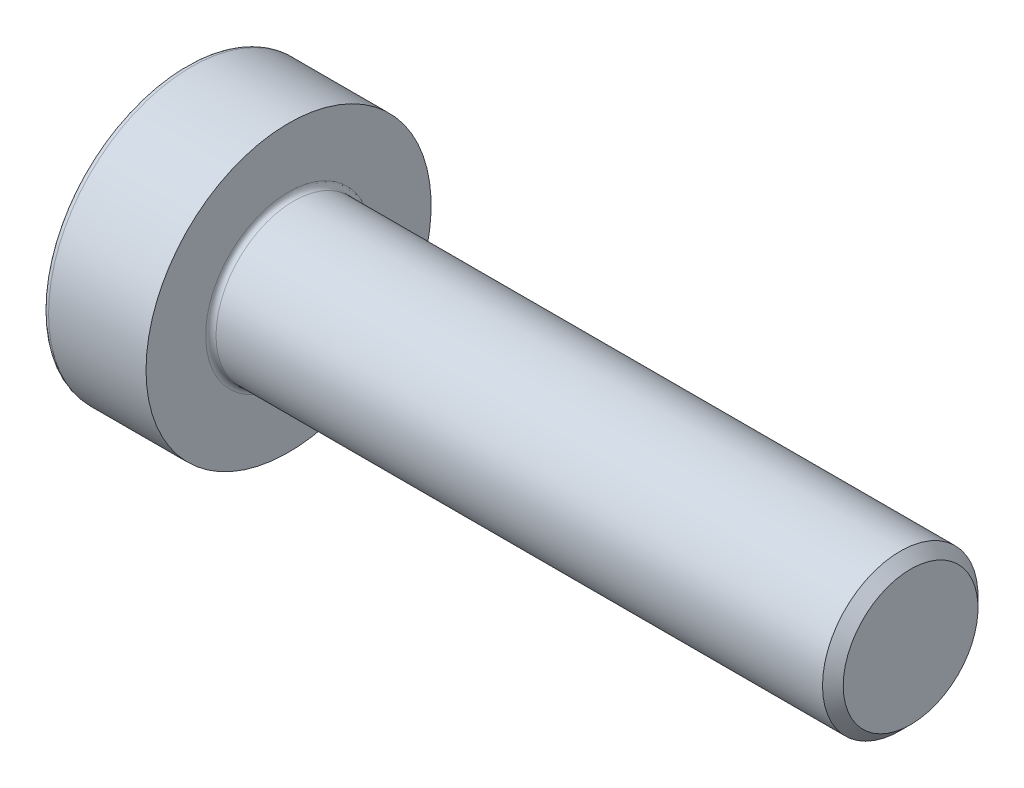
from build123d import *

# Parameters (mm, degrees)
FILLET1_R      = 0.1
FILLET2_R      = 0.12
CHAMFER1_SIZE  = 0.2
EXTRUDE1_DEPTH = 1


with BuildPart() as part:
    # Sketch1 → Revolve1 (revolve)
    with BuildSketch(Plane.XY, mode=Mode.PRIVATE) as revolve1_sk:
        Polygon((2, 1.5), (2, 0), (4.279914881, 0), (14, 0), (14, 1.5), align=None)
        Polygon((0, 2.75), (0, 0), (2, 0), (2, 1.5), (2, 2.75), align=None)
    revolve(revolve1_sk.sketch.rotate(Axis((0, 0, 0), (1, 0, 0)), 90), axis=Axis((0, 0, 0), (1, 0, 0)))

    # Fillet1
    fillet1_edges = [part.edges().sort_by_distance(p)[0] for p in [
        (2, 0, -1.5),
    ]]
    fillet(fillet1_edges, radius=FILLET1_R)

    # Fillet2
    fillet2_edges = [part.edges().sort_by_distance(p)[0] for p in [
        (0, 0, -2.75),
    ]]
    fillet(fillet2_edges, radius=FILLET2_R)

    # Chamfer1
    chamfer1_edges = [part.edges().sort_by_distance(p)[0] for p in [
        (14, 0, -1.5),
    ]]
    chamfer(chamfer1_edges, length=CHAMFER1_SIZE)

    # Sketch2 → Extrude1 (cut)
    with BuildSketch(Plane.ZY):
        Polygon((0, 1.443375673), (-1.25, 0.721687836), (-1.25, -0.721687836), (0, -1.443375673), (1.25, -0.721687836), (1.25, 0.721687836), align=None)
    extrude(amount=-EXTRUDE1_DEPTH, mode=Mode.SUBTRACT)


solid = part.part
